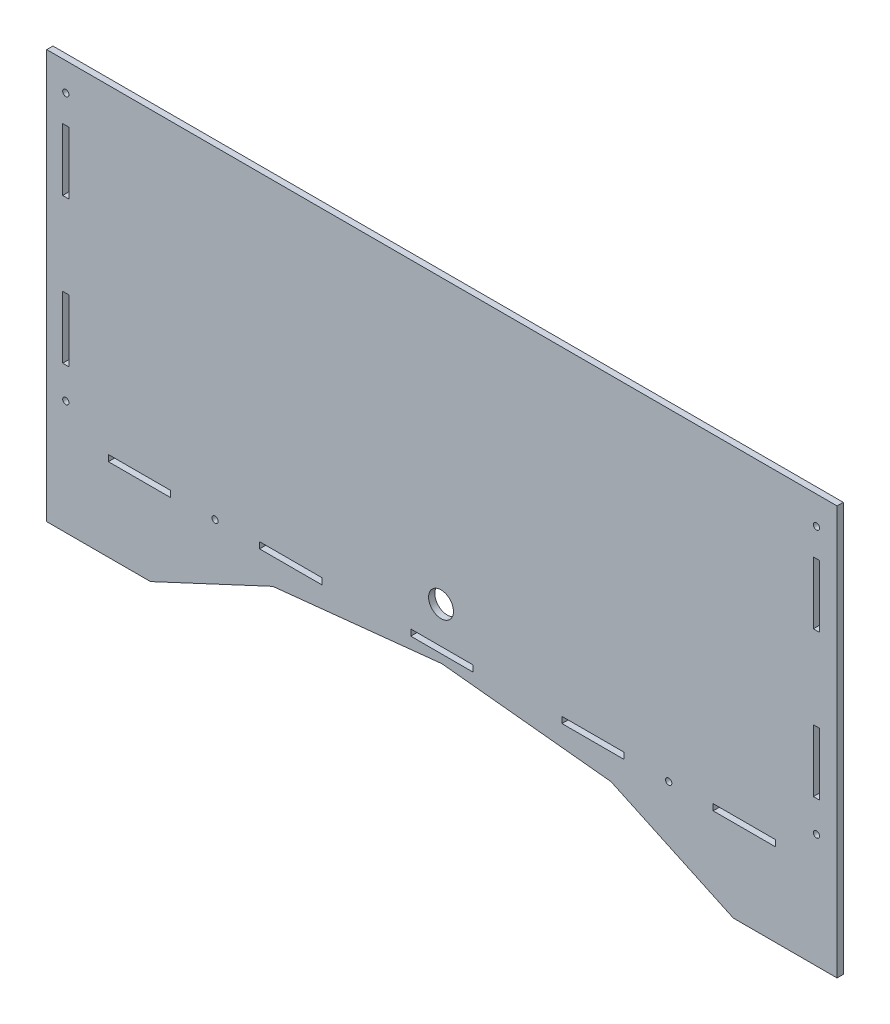
from build123d import *

# Parameters (mm, degrees)
SKETCH1_R           = 1.5
SKETCH1_R_2         = 6
SKETCH1_W           = 30
SKETCH1_H           = 3
SKETCH1_W_2         = 3
SKETCH1_H_2         = 30
BOSS_EXTRUDE1_DEPTH = 3


with BuildPart() as part:
    # Sketch1 → Boss-Extrude1 (new body)
    with BuildSketch(Plane(origin=(-12.611770594, -16.696126479, 0), x_dir=(0, -1, 0), z_dir=(0, 0, 1))):
        Polygon((-213.696126479, 12.611770594), (-213.696126479, 393.451770594), (-16.696126479, 393.451770594), (-16.696126479, 343.451770594), (-44.166313492, 284.541764437), (-52.636925092, 203.031770594), (-44.166313492, 121.521776752), (-16.696126479, 62.611770594), (-16.696126479, 12.611770594), align=None)
        with Locations((-200.179850585, 21.811770594)):
            Circle(SKETCH1_R, mode=Mode.SUBTRACT)
        with Locations((-58.093278212, 312.31748488)):
            Circle(SKETCH1_R, mode=Mode.SUBTRACT)
        with Locations((-200.196126479, 383.531770594)):
            Circle(SKETCH1_R, mode=Mode.SUBTRACT)
        with Locations((-71.696126479, 383.531770594)):
            Circle(SKETCH1_R, mode=Mode.SUBTRACT)
        with Locations((-58.136861316, 93.744627737)):
            Circle(SKETCH1_R, mode=Mode.SUBTRACT)
        with Locations((-71.679850585, 21.811770594)):
            Circle(SKETCH1_R, mode=Mode.SUBTRACT)
        with Locations((-77.241301287, 202.611770594)):
            Circle(SKETCH1_R_2, mode=Mode.SUBTRACT)
        with Locations((-171.679850585, 21.811770594)):
            Rectangle(SKETCH1_W, SKETCH1_H, mode=Mode.SUBTRACT)
        with Locations((-101.679850585, 21.811770594)):
            Rectangle(SKETCH1_W, SKETCH1_H, mode=Mode.SUBTRACT)
        with Locations((-58.093278212, 57.316056309)):
            Rectangle(SKETCH1_W_2, SKETCH1_H_2, mode=Mode.SUBTRACT)
        with Locations((-58.136861316, 130.173199166)):
            Rectangle(SKETCH1_W_2, SKETCH1_H_2, mode=Mode.SUBTRACT)
        with Locations((-58.136925092, 203.030342023)):
            Rectangle(SKETCH1_W_2, SKETCH1_H_2, mode=Mode.SUBTRACT)
        with Locations((-58.093278212, 275.88748488)):
            Rectangle(SKETCH1_W_2, SKETCH1_H_2, mode=Mode.SUBTRACT)
        with Locations((-58.093278212, 348.74748488)):
            Rectangle(SKETCH1_W_2, SKETCH1_H_2, mode=Mode.SUBTRACT)
        with Locations((-101.696126479, 383.531770594)):
            Rectangle(SKETCH1_W, SKETCH1_H, mode=Mode.SUBTRACT)
        with Locations((-171.696126479, 383.531770594)):
            Rectangle(SKETCH1_W, SKETCH1_H, mode=Mode.SUBTRACT)
    extrude(amount=BOSS_EXTRUDE1_DEPTH)


solid = part.part
